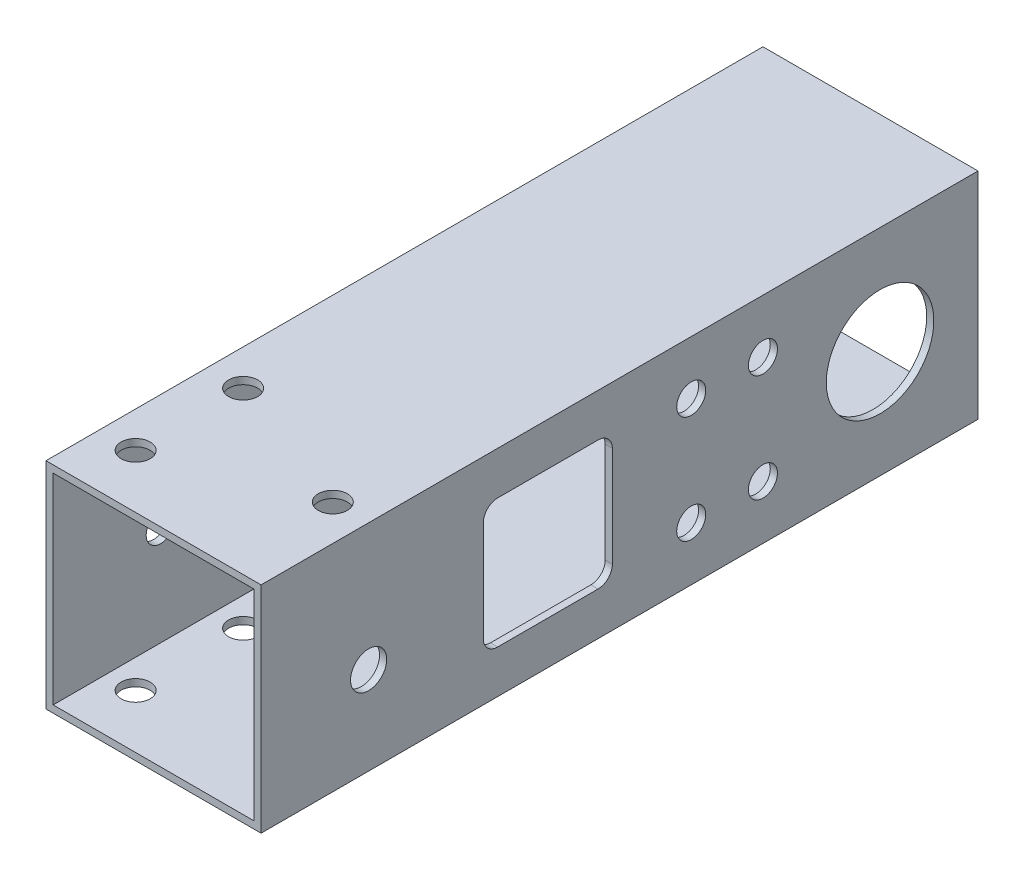
from build123d import *

# Parameters (mm, degrees)
SKETCH_1_W               = 30
SKETCH_1_H               = 30
EXTRUDE_1_DEPTH          = 50
SKETCH_2_W               = 28
SKETCH_2_H               = 28
CUT_EXTRUDE_1_DEPTH      = 1
CUT_EXTRUDE_1_DEPTH_BACK = 101
SKETCH_3_R               = 2.025
CUT_EXTRUDE_2_DEPTH      = 1
SKETCH_4_W               = 18
SKETCH_4_H               = 18
CUT_EXTRUDE_3_DEPTH      = 1
FILLET_1_R               = 2
CUT_EXTRUDE_START        = -2
SKETCH_5_R               = 2.025
CUT_EXTRUDE_5_DEPTH      = 32
SKETCH_6_R               = 2.025
CUT_EXTRUDE_6_DEPTH      = 1
CUT_EXTRUDE_6_DEPTH_BACK = 31
SKETCH_7_R               = 7.5
CUT_EXTRUDE_7_DEPTH      = 1
CUT_EXTRUDE_7_DEPTH_BACK = 31
SKETCH_8_R               = 2.025
CUT_EXTRUDE_8_DEPTH      = 1
CUT_EXTRUDE_8_DEPTH_BACK = 31
SKETCH_9_R               = 2.25
EXTRUDE_2_DEPTH          = 1
SKETCH_10_R              = 2.5
EXTRUDE_3_DEPTH          = 1
SKETCH_11_R              = 2.025
CUT_EXTRUDE_9_DEPTH      = 1
CUT_EXTRUDE_9_DEPTH_BACK = 31
SKETCH_12_R              = 2.5
EXTRUDE_4_DEPTH          = 1
CUT_EXTRUDE_10_REACH     = 32
SKETCH_13_R              = 2.525


with BuildPart() as part:
    # 草图1 → 凸台-拉伸1 (new body, symmetric)
    with BuildSketch(Plane.XY):
        Rectangle(SKETCH_1_W, SKETCH_1_H)
    extrude(amount=EXTRUDE_1_DEPTH, both=True)

    # 草图2 → 切除-拉伸1 (cut, two sides)
    with BuildSketch(Plane.XY.offset(50)) as cut_extrude_1_sk:
        Rectangle(SKETCH_2_W, SKETCH_2_H)
    extrude(amount=CUT_EXTRUDE_1_DEPTH, mode=Mode.SUBTRACT)
    extrude(cut_extrude_1_sk.sketch, amount=-CUT_EXTRUDE_1_DEPTH_BACK, mode=Mode.SUBTRACT)

    # 草图3 → 切除-拉伸2 (cut)
    with BuildSketch(Plane.ZY.offset(15)):
        with Locations((10, 0)):
            Circle(SKETCH_3_R)
        with Locations((35, 0)):
            Circle(SKETCH_3_R)
    extrude(amount=-CUT_EXTRUDE_2_DEPTH, mode=Mode.SUBTRACT)

    # 草图4 → 切除-拉伸3 (cut)
    with BuildSketch(Plane.ZY.offset(-14)):
        with Locations((10, 0)):
            Rectangle(SKETCH_4_W, SKETCH_4_H)
    extrude(amount=-CUT_EXTRUDE_3_DEPTH, mode=Mode.SUBTRACT)

    # 圆角1
    fillet_1_edges = [part.edges().sort_by_distance(p)[0] for p in [
        (14.5, 9, 19),
        (14.5, -9, 19),
        (14.5, -9, 1),
        (14.5, 9, 1),
    ]]
    fillet(fillet_1_edges, radius=FILLET_1_R)

    # 草图5 → 切除-拉伸5 (cut)
    with BuildSketch(Plane(origin=(0, -14, 0), x_dir=(1, 0, 0), z_dir=(0, 1, 0)).offset(CUT_EXTRUDE_START)):
        with Locations((-10, -27.5)):
            Circle(SKETCH_5_R)
        with Locations((-10, -42.5)):
            Circle(SKETCH_5_R)
    cut_extrude_5 = extrude(amount=CUT_EXTRUDE_5_DEPTH, mode=Mode.SUBTRACT)

    # 镜向1: 切除-拉伸5 across plane
    add(cut_extrude_5.mirror(Plane(origin=(0, 0, 0), x_dir=(0, 0, 1), z_dir=(1, 0, 0))), mode=Mode.SUBTRACT)

    # 草图6 → 切除-拉伸6 (cut, two sides)
    with BuildSketch(Plane.ZY.offset(15)) as cut_extrude_6_sk:
        with Locations((35, 0)):
            Circle(SKETCH_6_R)
        with Locations((-20, -7.5)):
            Circle(SKETCH_6_R)
        with Locations((-20, 7.5)):
            Circle(SKETCH_6_R)
    extrude(amount=CUT_EXTRUDE_6_DEPTH, mode=Mode.SUBTRACT)
    extrude(cut_extrude_6_sk.sketch, amount=-CUT_EXTRUDE_6_DEPTH_BACK, mode=Mode.SUBTRACT)

    # 草图7 → 切除-拉伸7 (cut, two sides)
    with BuildSketch(Plane.ZY.offset(15)) as cut_extrude_7_sk:
        with Locations((-36.341476857, 0)):
            Circle(SKETCH_7_R)
    extrude(amount=CUT_EXTRUDE_7_DEPTH, mode=Mode.SUBTRACT)
    extrude(cut_extrude_7_sk.sketch, amount=-CUT_EXTRUDE_7_DEPTH_BACK, mode=Mode.SUBTRACT)

    # 草图8 → 切除-拉伸8 (cut, two sides)
    with BuildSketch(Plane.ZY.offset(15)) as cut_extrude_8_sk:
        with Locations((-10, 7.5)):
            Circle(SKETCH_8_R)
        with Locations((-10, -7.5)):
            Circle(SKETCH_8_R)
    extrude(amount=CUT_EXTRUDE_8_DEPTH, mode=Mode.SUBTRACT)
    extrude(cut_extrude_8_sk.sketch, amount=-CUT_EXTRUDE_8_DEPTH_BACK, mode=Mode.SUBTRACT)

    # 草图9 → 凸台-拉伸2 (add)
    with BuildSketch(Plane(origin=(0, 15, 0), x_dir=(1, 0, 0), z_dir=(0, 1, 0))):
        with Locations((10, -27.5)):
            Circle(SKETCH_9_R)
        with Locations((10, -42.5)):
            Circle(SKETCH_9_R)
    extrude(amount=-EXTRUDE_2_DEPTH)

    # 草图10 → 凸台-拉伸3 (add)
    with BuildSketch(Plane.XZ.offset(15)):
        with Locations((10, 42.5)):
            Circle(SKETCH_10_R)
        with Locations((10, 27.5)):
            Circle(SKETCH_10_R)
    extrude(amount=-EXTRUDE_3_DEPTH)

    # 草图11 → 切除-拉伸9 (cut, two sides)
    with BuildSketch(Plane(origin=(0, 15, 0), x_dir=(1, 0, 0), z_dir=(0, 1, 0))) as cut_extrude_9_sk:
        with Locations((10, -35)):
            Circle(SKETCH_11_R)
    extrude(amount=CUT_EXTRUDE_9_DEPTH, mode=Mode.SUBTRACT)
    extrude(cut_extrude_9_sk.sketch, amount=-CUT_EXTRUDE_9_DEPTH_BACK, mode=Mode.SUBTRACT)

    # 草图12 → 凸台-拉伸4 (add)
    with BuildSketch(Plane(origin=(15, 0, 0), x_dir=(0, 0, -1), z_dir=(1, 0, 0))):
        with Locations((-35, 0)):
            Circle(SKETCH_12_R)
    extrude(amount=-EXTRUDE_4_DEPTH)

    # 草图13 → 切除-拉伸10 (cut, up to next)
    with BuildSketch(Plane(origin=(15, 0, 0), x_dir=(0, 0, -1), z_dir=(1, 0, 0)), mode=Mode.PRIVATE) as cut_extrude_10_sk1:
        with Locations((-35, -2.75)):
            Circle(SKETCH_13_R)
    cut_extrude_10_tool1 = extrude(cut_extrude_10_sk1.sketch, amount=-CUT_EXTRUDE_10_REACH, mode=Mode.PRIVATE) & part.part
    add(cut_extrude_10_tool1.solids().sort_by_distance((15, -2.75, 35))[0], mode=Mode.SUBTRACT)


solid = part.part
